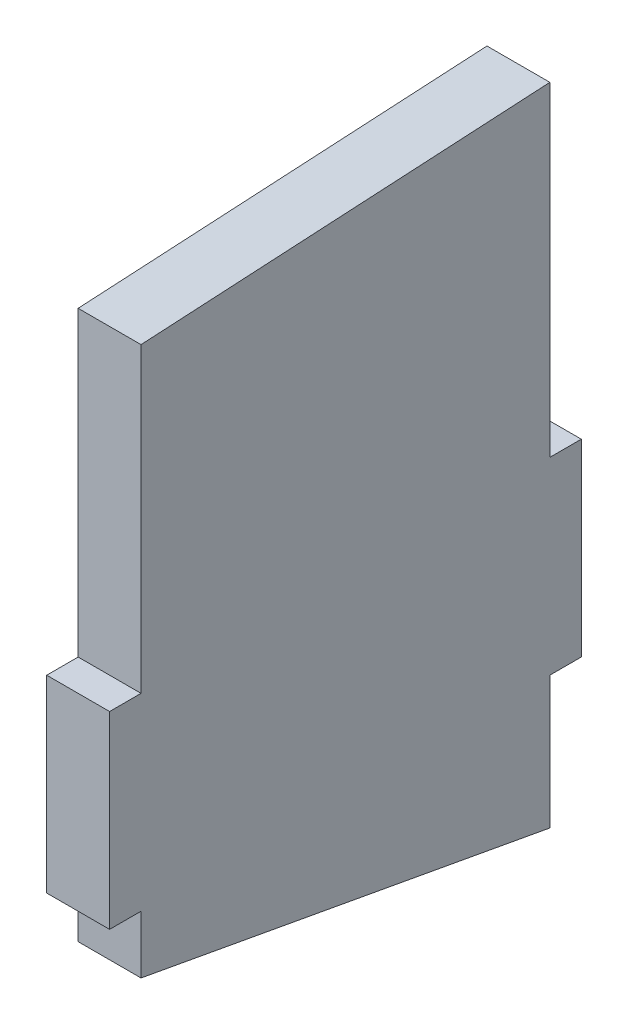
from build123d import *

# Parameters (mm, degrees)
SKETCH1_W           = 12.7
SKETCH1_H           = 76.2
SKETCH1_W_2         = 165.1
BOSS_EXTRUDE1_DEPTH = 25.4


with BuildPart() as part:
    # Sketch1 → Boss-Extrude1 (new body)
    with BuildSketch(Plane(origin=(0, 0, 0), x_dir=(0, 0, -1), z_dir=(1, 0, 0))):
        Polygon((82.55, 169.255785694), (-82.55, 160.06891278), (-82.55, 38.1), (82.55, 38.1), align=None)
        with Locations((88.9, 0)):
            Rectangle(SKETCH1_W, SKETCH1_H)
        Rectangle(SKETCH1_W_2, SKETCH1_H)
        with Locations((-88.9, 0)):
            Rectangle(SKETCH1_W, SKETCH1_H)
        Polygon((82.55, -38.1), (-82.55, -38.1), (-82.55, -61.45546637), (82.55, -91.545497884), align=None)
    extrude(amount=BOSS_EXTRUDE1_DEPTH)


solid = part.part
